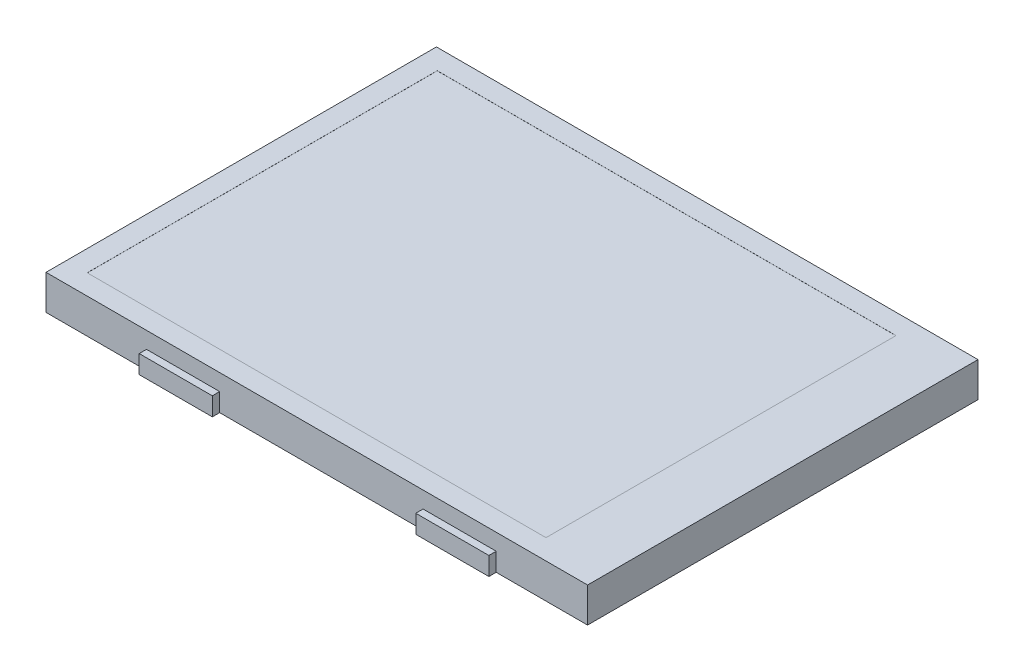
from build123d import *

# Parameters (mm, degrees)
SKETCH1_W           = 59.26
SKETCH1_H           = 42.72
BOSS_EXTRUDE1_DEPTH = 3.8
SKETCH2_W           = 8
SKETCH2_H           = 2
BOSS_EXTRUDE2_DEPTH = 0.8
SKETCH3_W           = 8
SKETCH3_H           = 2
BOSS_EXTRUDE3_DEPTH = 0.8
SKETCH4_W           = 50.2
SKETCH4_H           = 38.3
CUT_EXTRUDE1_DEPTH  = 0.01


with BuildPart() as part:
    # Sketch1 → Boss-Extrude1 (new body)
    with BuildSketch(Plane(origin=(0, 0, 0), x_dir=(1, 0, 0), z_dir=(0, 1, 0))):
        Rectangle(SKETCH1_W, SKETCH1_H)
    extrude(amount=BOSS_EXTRUDE1_DEPTH)

    # Sketch2 → Boss-Extrude2 (add)
    with BuildSketch(Plane.XY.offset(21.36)):
        with Locations((-14.63, 1)):
            Rectangle(SKETCH2_W, SKETCH2_H)
        with Locations((15.63, 1)):
            Rectangle(SKETCH2_W, SKETCH2_H)
    extrude(amount=BOSS_EXTRUDE2_DEPTH)

    # Sketch3 → Boss-Extrude3 (add)
    with BuildSketch(Plane(origin=(0, 0, -21.36), x_dir=(-1, 0, 0), z_dir=(0, 0, -1))):
        with Locations((14.63, 1)):
            Rectangle(SKETCH3_W, SKETCH3_H)
        with Locations((-15.63, 1)):
            Rectangle(SKETCH3_W, SKETCH3_H)
    extrude(amount=BOSS_EXTRUDE3_DEPTH)

    # Sketch4 → Cut-Extrude1 (cut)
    with BuildSketch(Plane(origin=(0, 3.8, 0), x_dir=(1, 0, 0), z_dir=(0, 1, 0))):
        with Locations((-2.23, 0)):
            Rectangle(SKETCH4_W, SKETCH4_H)
    extrude(amount=-CUT_EXTRUDE1_DEPTH, mode=Mode.SUBTRACT)


solid = part.part
